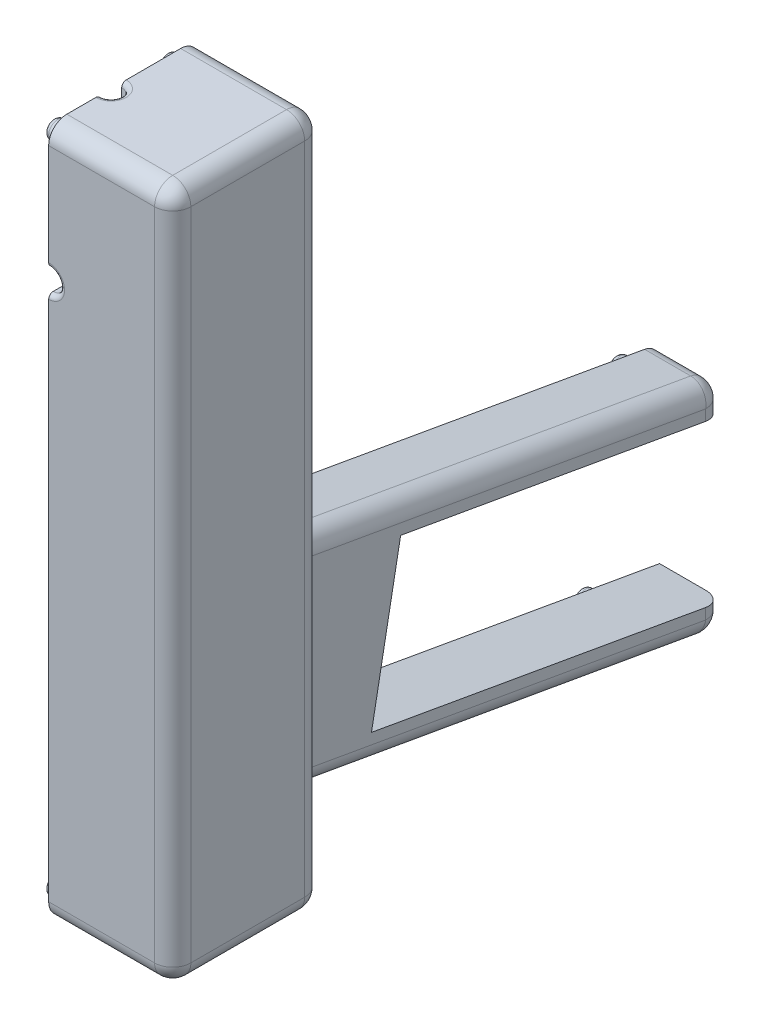
from build123d import *

# Parameters (mm, degrees)
SKETCH1_W                = 27.35
SKETCH1_H                = 33.1
BOSS_EXTRUDE1_DEPTH      = 152.4
SKETCH2_W                = 20.4
SKETCH2_H                = 139.7
CUT_EXTRUDE1_DEPTH       = 21
HITLED_REACH             = 35.1
SKETCH6_W                = 6.35
SKETCH6_H                = 74.93
PCB_DEPTH                = 6.35
SKETCH16_R               = 2
PRESSFIT_DEPTH           = 3
FILLET_PRESSFIT_R        = 1
BUTT_DEPTH               = 14.175
BATTERYPACK_DEPTH        = 14.175
SKETCH22_R               = 2
PRESSFIT_BOTTOM_DEPTH    = 3
IRLED_REACH              = 8.35
FILLET_BODY_R            = 4
FILLET_PRESSFIT_BOTTOM_R = 1
FILLET_LED_S_R           = 1
CUT_EXTRUDE2_DEPTH       = 3.5
CUT_EXTRUDE3_DEPTH       = 12.065
CUT_EXTRUDE4_DEPTH       = 10.825


with BuildPart() as part:
    # Sketch1 → Boss-Extrude1 (new body)
    with BuildSketch(Plane(origin=(0, 0, 0), x_dir=(1, 0, 0), z_dir=(0, 1, 0))):
        with Locations((13.675, 16.55)):
            Rectangle(SKETCH1_W, SKETCH1_H)
    extrude(amount=BOSS_EXTRUDE1_DEPTH)

    # Sketch2 → Cut-Extrude1 (cut)
    with BuildSketch(Plane.ZY):
        with Locations((-16.55, 76.2)):
            Rectangle(SKETCH2_W, SKETCH2_H)
    extrude(amount=-CUT_EXTRUDE1_DEPTH, mode=Mode.SUBTRACT)

    # Sketch3 → HitLED (cut, up to next)
    with BuildSketch(Plane.XY, mode=Mode.PRIVATE) as hitled_sk1:
        with BuildLine():
            Line((0, 125.055), (0, 120.055))
            ThreePointArc((0, 120.055), (2.5, 122.555), (0, 125.055))
        make_face()
    hitled_tool1 = extrude(hitled_sk1.sketch, amount=-HITLED_REACH, mode=Mode.PRIVATE) & part.part
    add(hitled_tool1.solids().sort_by_distance((1.061033, 122.555, 0))[0], mode=Mode.SUBTRACT)

    # Sketch6 → PCB (add)
    with BuildSketch(Plane.ZY.offset(-21)):
        with Locations((-12.525, 70.485)):
            Rectangle(SKETCH6_W, SKETCH6_H)
        with Locations((-20.575, 70.485)):
            Rectangle(SKETCH6_W, SKETCH6_H)
    extrude(amount=PCB_DEPTH)

    # Sketch16 → PressFit (add)
    with BuildSketch(Plane.ZY):
        with Locations((-4, 148.4)):
            Circle(SKETCH16_R)
        with Locations((-4, 4)):
            Circle(SKETCH16_R)
        with Locations((-29.1, 148.4)):
            Circle(SKETCH16_R)
        with Locations((-29.1, 4)):
            Circle(SKETCH16_R)
    extrude(amount=PRESSFIT_DEPTH)

    # Fillet-PressFit
    fillet_pressfit_edges = [part.edges().sort_by_distance(p)[0] for p in [
        (-3, 148.4, -6),
        (-3, 4, -6),
        (-3, 148.4, -31.1),
        (-3, 4, -31.1),
    ]]
    fillet(fillet_pressfit_edges, radius=FILLET_PRESSFIT_R)

    # Sketch23 → Butt (add)
    with BuildSketch(Plane(origin=(0, 0, -25.4), x_dir=(0, 0, 1), z_dir=(-1, 0, 0))):
        Polygon((-7.7, 61.135849387), (-7.7, 12.7), (-109.3, -5.21482124), (-109.3, 43.221028147), align=None)
    extrude(amount=-BUTT_DEPTH)

    # Sketch20 → BatteryPack (cut)
    with BuildSketch(Plane.ZY):
        Polygon((-63.435596448, 49.338906272), (-57.003300004, 14.933162267), (-123.973771116, 3.124461299), (-134.7, 1.233137745), (-134.7, 36.773069161), (-130.40606756, 37.530205304), align=None)
    extrude(amount=-BATTERYPACK_DEPTH, mode=Mode.SUBTRACT)

    # Sketch22 → PressFit - Bottom (add)
    with BuildSketch(Plane.ZY):
        with Locations((-128.066987256, 41.166627764)):
            Circle(SKETCH22_R)
        with Locations((-120.442926047, 0.523065057)):
            Circle(SKETCH22_R)
    extrude(amount=PRESSFIT_BOTTOM_DEPTH)

    # Sketch25 → IRLED (cut, up to next)
    with BuildSketch(Plane.XZ.offset(-146.05), mode=Mode.PRIVATE) as irled_sk1:
        with BuildLine():
            Line((0, -11.4), (0, -16.1))
            ThreePointArc((0, -16.1), (2.35, -13.75), (0, -11.4))
        make_face()
    irled_tool1 = extrude(irled_sk1.sketch, amount=-IRLED_REACH, mode=Mode.PRIVATE) & part.part
    add(irled_tool1.solids().sort_by_distance((0.997371, 146.05, -13.75))[0], mode=Mode.SUBTRACT)

    # Fillet - Body
    fillet_body_edges = [part.edges().sort_by_distance(p)[0] for p in [
        (14.175, -1.990841747, -134.7),
        (27.35, 152.4, -16.55),
        (13.675, 152.4, -33.1),
        (13.675, 0, -33.1),
        (27.35, 0, -16.55),
        (13.675, 0, 0),
        (27.35, 76.2, -33.1),
        (27.35, 76.2, 0),
        (13.675, 152.4, 0),
        (14.175, 52.178438767, -83.9),
        (7.0875, 43.221028147, -134.7),
        (14.175, 36.917924693, -33.1),
        (7.0875, 61.135849387, -33.1),
        (14.175, 3.74258938, -83.9),
        (7.0875, 12.7, -33.1),
        (14.175, 39.997048654, -134.7),
        (7.0875, -5.21482124, -134.7),
    ]]
    fillet(fillet_body_edges, radius=FILLET_BODY_R)

    # Fillet-PressFit-Bottom
    fillet_pressfit_bottom_edges = [part.edges().sort_by_distance(p)[0] for p in [
        (-3, 41.166627764, -130.066987256),
        (-3, 0.523065057, -122.442926047),
    ]]
    fillet(fillet_pressfit_bottom_edges, radius=FILLET_PRESSFIT_BOTTOM_R)

    # Fillet-LED's
    fillet_led_s_edges = [part.edges().sort_by_distance(p)[0] for p in [
        (2.35, 152.4, -13.75),
        (2.5, 122.555, 0),
    ]]
    fillet(fillet_led_s_edges, radius=FILLET_LED_S_R)

    # Sketch26 → Cut-Extrude2 (cut)
    with BuildSketch(Plane.ZY):
        Polygon((-46.717974009, 58.734633147), (-53.61162828, 57.519095903), (-52.986494841, 53.973787992), (-46.09284057, 55.189325236), align=None)
    extrude(amount=-CUT_EXTRUDE2_DEPTH, mode=Mode.SUBTRACT)

    # Sketch27 → Cut-Extrude3 (cut)
    with BuildSketch(Plane.ZY):
        Polygon((-40.159373858, 56.235555506), (-58.919961553, 52.927557722), (-58.62475965, 51.253384541), (-39.864171956, 54.561382326), align=None)
    extrude(amount=-CUT_EXTRUDE3_DEPTH, mode=Mode.SUBTRACT)

    # Sketch28 → Cut-Extrude4 (cut)
    with BuildSketch(Plane.ZY):
        Polygon((-43.335619285, 53.9492725), (-55.153312321, 51.865494368), (-48.893295516, 16.363174872), (-37.07560248, 18.446953004), align=None)
    extrude(amount=-CUT_EXTRUDE4_DEPTH, mode=Mode.SUBTRACT)


solid = part.part
